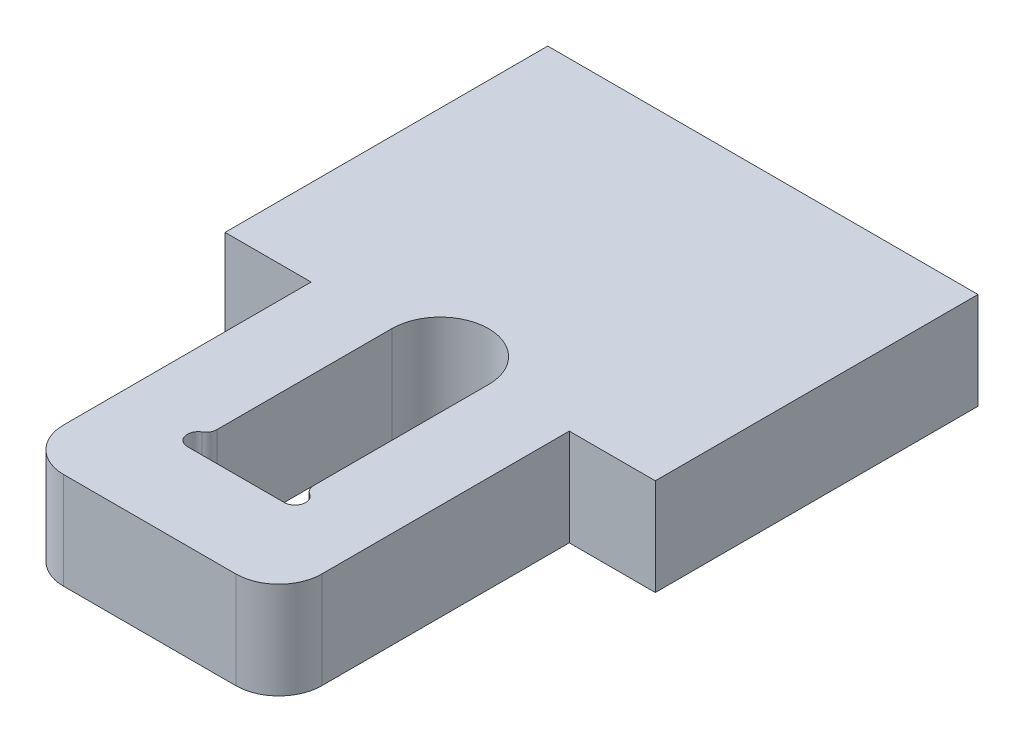
from build123d import *

# Parameters (mm, degrees)
BOSS_EXTRUDE1_DEPTH = 4.5


with BuildPart() as part:
    # Sketch1 → Boss-Extrude1 (new body)
    with BuildSketch(Plane(origin=(0, 0, 0), x_dir=(1, 0, 0), z_dir=(0, 1, 0))):
        with BuildLine():
            Line((-10, 0), (-10, 15))
            Line((-10, 15), (10, 15))
            Line((10, 15), (10, 0))
            Line((10, 0), (6, 0))
            Line((6, 0), (6, -11.5))
            ThreePointArc((6, -11.5), (5.414213562, -12.914213562), (4, -13.5))
            Line((4, -13.5), (-4, -13.5))
            ThreePointArc((-4, -13.5), (-5.414213562, -12.914213562), (-6, -11.5))
            Line((-6, -11.5), (-6, 0))
            Line((-6, 0), (-10, 0))
        make_face()
        with BuildLine():
            Line((2.25, 0), (2.25, -8.133974596))
            ThreePointArc((2.25, -8.133974596), (2.316987298, -8.383974596), (2.5, -8.566987298))
            ThreePointArc((2.5, -8.566987298), (2.732962913, -9.129409523), (2.25, -9.5))
            Line((2.25, -9.5), (-2.25, -9.5))
            ThreePointArc((-2.25, -9.5), (-2.732962913, -9.129409523), (-2.5, -8.566987298))
            ThreePointArc((-2.5, -8.566987298), (-2.316987298, -8.383974596), (-2.25, -8.133974596))
            Line((-2.25, -8.133974596), (-2.25, 0))
            ThreePointArc((-2.25, 0), (0, 2.25), (2.25, 0))
        make_face(mode=Mode.SUBTRACT)
    extrude(amount=BOSS_EXTRUDE1_DEPTH)


solid = part.part
